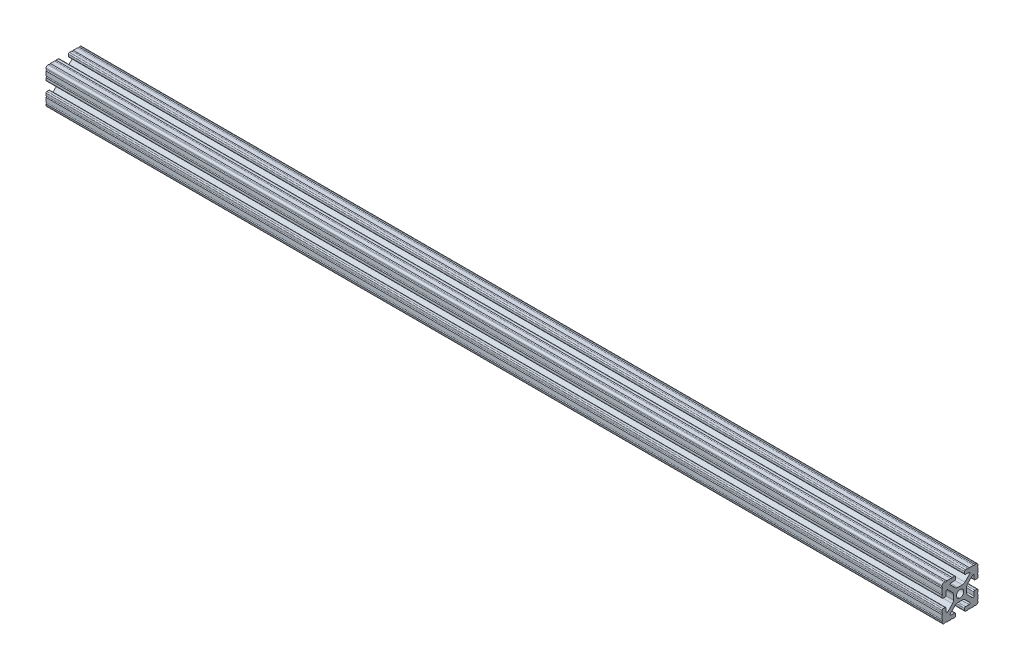
from build123d import *

# Parameters (mm, degrees)
SKETCH2_R           = 2.6035
BOSS_EXTRUDE1_DEPTH = 635


with BuildPart() as part:
    # Sketch2 → Boss-Extrude1 (new body)
    with BuildSketch(Plane(origin=(0, 0, 0), x_dir=(0, 0, -1), z_dir=(1, 0, 0))):
        with BuildLine():
            ThreePointArc((14.334948438, 8.074367167), (15.301384825, 7.882131017), (16.120690033, 7.33468878))
            Line((16.120690033, 7.33468878), (19.543976403, 3.911402409))
            ThreePointArc((19.543976403, 3.911402409), (19.684847869, 3.203193724), (19.084457536, 2.802025729))
            Line((19.084457536, 2.802025729), (16.63615869, 2.802025729))
            ThreePointArc((16.63615869, 2.802025729), (16.142839499, 2.59768623), (15.9385, 2.10436704))
            Line((15.9385, 2.10436704), (15.9385, 0.69765869))
            ThreePointArc((15.9385, 0.69765869), (16.142839499, 0.204339499), (16.63615869, 0))
            Line((16.63615869, 0), (18.269856434, 0))
            ThreePointArc((18.269856434, 0), (18.756204355, 0.361269978), (19.242552277, 0))
            Line((19.242552277, 0), (22.318048746, 0))
            ThreePointArc((22.318048746, 0), (22.808739066, 0.376519925), (23.299429386, 0))
            Line((23.299429386, 0), (24.052572236, 0))
            ThreePointArc((24.052572236, 0), (25.005347545, 0.394652455), (25.4, 1.347427764))
            Line((25.4, 1.347427764), (25.4, 2.100570614))
            ThreePointArc((25.4, 2.100570614), (25.023480075, 2.591260934), (25.4, 3.081951254))
            Line((25.4, 3.081951254), (25.4, 6.157447723))
            ThreePointArc((25.4, 6.157447723), (25.038730022, 6.643795645), (25.4, 7.130143566))
            Line((25.4, 7.130143566), (25.4, 8.76384131))
            ThreePointArc((25.4, 8.76384131), (25.195660501, 9.257160501), (24.70234131, 9.4615))
            Line((24.70234131, 9.4615), (23.29563296, 9.4615))
            ThreePointArc((23.29563296, 9.4615), (22.80231377, 9.257160501), (22.597974271, 8.76384131))
            Line((22.597974271, 8.76384131), (22.597974271, 6.315542464))
            ThreePointArc((22.597974271, 6.315542464), (22.196806276, 5.715152131), (21.488597591, 5.856023597))
            Line((21.488597591, 5.856023597), (18.06531122, 9.279309967))
            ThreePointArc((18.06531122, 9.279309967), (17.517868983, 10.098615175), (17.325632833, 11.065051562))
            Line((17.325632833, 11.065051562), (17.325632833, 14.334948438))
            ThreePointArc((17.325632833, 14.334948438), (17.517868983, 15.301384825), (18.06531122, 16.120690033))
            Line((18.06531122, 16.120690033), (21.488597591, 19.543976403))
            ThreePointArc((21.488597591, 19.543976403), (22.196806276, 19.684847869), (22.597974271, 19.084457536))
            Line((22.597974271, 19.084457536), (22.597974271, 16.63615869))
            ThreePointArc((22.597974271, 16.63615869), (22.80231377, 16.142839499), (23.29563296, 15.9385))
            Line((23.29563296, 15.9385), (24.70234131, 15.9385))
            ThreePointArc((24.70234131, 15.9385), (25.195660501, 16.142839499), (25.4, 16.63615869))
            Line((25.4, 16.63615869), (25.4, 18.269856434))
            ThreePointArc((25.4, 18.269856434), (25.038730022, 18.756204355), (25.4, 19.242552277))
            Line((25.4, 19.242552277), (25.4, 22.318048746))
            ThreePointArc((25.4, 22.318048746), (25.023480075, 22.808739066), (25.4, 23.299429386))
            Line((25.4, 23.299429386), (25.4, 24.052572236))
            ThreePointArc((25.4, 24.052572236), (25.005347545, 25.005347545), (24.052572236, 25.4))
            Line((24.052572236, 25.4), (23.299429386, 25.4))
            ThreePointArc((23.299429386, 25.4), (22.808739066, 25.023480075), (22.318048746, 25.4))
            Line((22.318048746, 25.4), (19.242552277, 25.4))
            ThreePointArc((19.242552277, 25.4), (18.756204355, 25.038730022), (18.269856434, 25.4))
            Line((18.269856434, 25.4), (16.63615869, 25.4))
            ThreePointArc((16.63615869, 25.4), (16.142839499, 25.195660501), (15.9385, 24.70234131))
            Line((15.9385, 24.70234131), (15.9385, 23.29563296))
            ThreePointArc((15.9385, 23.29563296), (16.142839499, 22.80231377), (16.63615869, 22.597974271))
            Line((16.63615869, 22.597974271), (19.084457536, 22.597974271))
            ThreePointArc((19.084457536, 22.597974271), (19.684847869, 22.196806276), (19.543976403, 21.488597591))
            Line((19.543976403, 21.488597591), (16.120690033, 18.06531122))
            ThreePointArc((16.120690033, 18.06531122), (15.301384825, 17.517868983), (14.334948438, 17.325632833))
            Line((14.334948438, 17.325632833), (11.065051562, 17.325632833))
            ThreePointArc((11.065051562, 17.325632833), (10.098615175, 17.517868983), (9.279309967, 18.06531122))
            Line((9.279309967, 18.06531122), (5.856023597, 21.488597591))
            ThreePointArc((5.856023597, 21.488597591), (5.715152131, 22.196806276), (6.315542464, 22.597974271))
            Line((6.315542464, 22.597974271), (8.76384131, 22.597974271))
            ThreePointArc((8.76384131, 22.597974271), (9.257160501, 22.80231377), (9.4615, 23.29563296))
            Line((9.4615, 23.29563296), (9.4615, 24.70234131))
            ThreePointArc((9.4615, 24.70234131), (9.257160501, 25.195660501), (8.76384131, 25.4))
            Line((8.76384131, 25.4), (7.130143566, 25.4))
            ThreePointArc((7.130143566, 25.4), (6.643795645, 25.038730022), (6.157447723, 25.4))
            Line((6.157447723, 25.4), (3.081951254, 25.4))
            ThreePointArc((3.081951254, 25.4), (2.591260934, 25.023480075), (2.100570614, 25.4))
            Line((2.100570614, 25.4), (1.347427764, 25.4))
            ThreePointArc((1.347427764, 25.4), (0.394652455, 25.005347545), (0, 24.052572236))
            Line((0, 24.052572236), (0, 23.299429386))
            ThreePointArc((0, 23.299429386), (0.376519925, 22.808739066), (0, 22.318048746))
            Line((0, 22.318048746), (0, 19.242552277))
            ThreePointArc((0, 19.242552277), (0.361269978, 18.756204355), (0, 18.269856434))
            Line((0, 18.269856434), (0, 16.63615869))
            ThreePointArc((0, 16.63615869), (0.204339499, 16.142839499), (0.69765869, 15.9385))
            Line((0.69765869, 15.9385), (2.10436704, 15.9385))
            ThreePointArc((2.10436704, 15.9385), (2.59768623, 16.142839499), (2.802025729, 16.63615869))
            Line((2.802025729, 16.63615869), (2.802025729, 19.084457536))
            ThreePointArc((2.802025729, 19.084457536), (3.203193724, 19.684847869), (3.911402409, 19.543976403))
            Line((3.911402409, 19.543976403), (7.33468878, 16.120690033))
            ThreePointArc((7.33468878, 16.120690033), (7.882131017, 15.301384825), (8.074367167, 14.334948438))
            Line((8.074367167, 14.334948438), (8.074367167, 11.065051562))
            ThreePointArc((8.074367167, 11.065051562), (7.882131017, 10.098615175), (7.33468878, 9.279309967))
            Line((7.33468878, 9.279309967), (3.911402409, 5.856023597))
            ThreePointArc((3.911402409, 5.856023597), (3.203193724, 5.715152131), (2.802025729, 6.315542464))
            Line((2.802025729, 6.315542464), (2.802025729, 8.76384131))
            ThreePointArc((2.802025729, 8.76384131), (2.59768623, 9.257160501), (2.10436704, 9.4615))
            Line((2.10436704, 9.4615), (0.69765869, 9.4615))
            ThreePointArc((0.69765869, 9.4615), (0.204339499, 9.257160501), (0, 8.76384131))
            Line((0, 8.76384131), (0, 7.130143566))
            ThreePointArc((0, 7.130143566), (0.361269978, 6.643795645), (0, 6.157447723))
            Line((0, 6.157447723), (0, 3.081951254))
            ThreePointArc((0, 3.081951254), (0.376519925, 2.591260934), (0, 2.100570614))
            Line((0, 2.100570614), (0, 1.347427764))
            ThreePointArc((0, 1.347427764), (0.394652455, 0.394652455), (1.347427764, 0))
            Line((1.347427764, 0), (2.100570614, 0))
            ThreePointArc((2.100570614, 0), (2.591260934, 0.376519925), (3.081951254, 0))
            Line((3.081951254, 0), (6.157447723, 0))
            ThreePointArc((6.157447723, 0), (6.643795645, 0.361269978), (7.130143566, 0))
            Line((7.130143566, 0), (8.76384131, 0))
            ThreePointArc((8.76384131, 0), (9.257160501, 0.204339499), (9.4615, 0.69765869))
            Line((9.4615, 0.69765869), (9.4615, 2.10436704))
            ThreePointArc((9.4615, 2.10436704), (9.257160501, 2.59768623), (8.76384131, 2.802025729))
            Line((8.76384131, 2.802025729), (6.315542464, 2.802025729))
            ThreePointArc((6.315542464, 2.802025729), (5.715152131, 3.203193724), (5.856023597, 3.911402409))
            Line((5.856023597, 3.911402409), (9.279309967, 7.33468878))
            ThreePointArc((9.279309967, 7.33468878), (10.098615175, 7.882131017), (11.065051562, 8.074367167))
            Line((11.065051562, 8.074367167), (14.334948438, 8.074367167))
        make_face()
        with Locations((12.7, 12.7)):
            Circle(SKETCH2_R, mode=Mode.SUBTRACT)
    extrude(amount=BOSS_EXTRUDE1_DEPTH)


with BuildPart() as part_1:
    # Body-Move/Copy1: moved
    add(part.part.moved(Location((-150.058747395, 28.75970044, 59.645039801))))


solid = part_1.part
